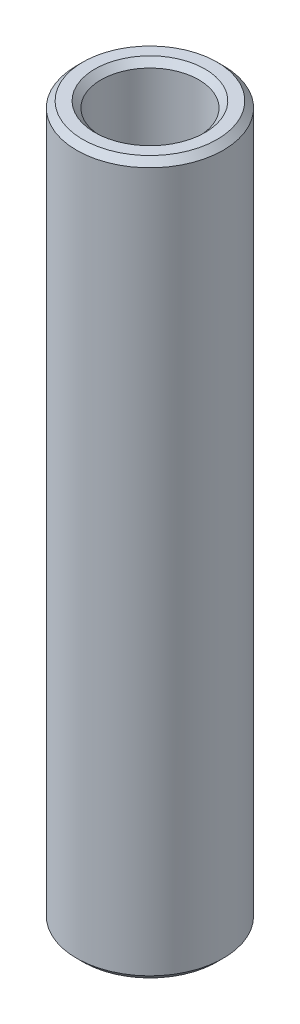
from build123d import *

# Parameters (mm, degrees)
SKETCH2_W     = 1
SKETCH2_H     = 29.1465
CHAMFER2_SIZE = 0.254


with BuildPart() as part:
    # Sketch2 → Revolve1 (revolve)
    with BuildSketch(Plane.XY):
        with Locations((2.5, 0)):
            Rectangle(SKETCH2_W, SKETCH2_H)
    revolve(axis=Axis((0, 9.961653463, 0), (0, -1, 0)))

    # Chamfer2
    chamfer2_edges = [part.edges().sort_by_distance(p)[0] for p in [
        (-3, 14.57325, 0),
        (-3, -14.57325, 0),
        (-2, -14.57325, 0),
        (-2, 14.57325, 0),
    ]]
    chamfer(chamfer2_edges, length=CHAMFER2_SIZE)


solid = part.part
